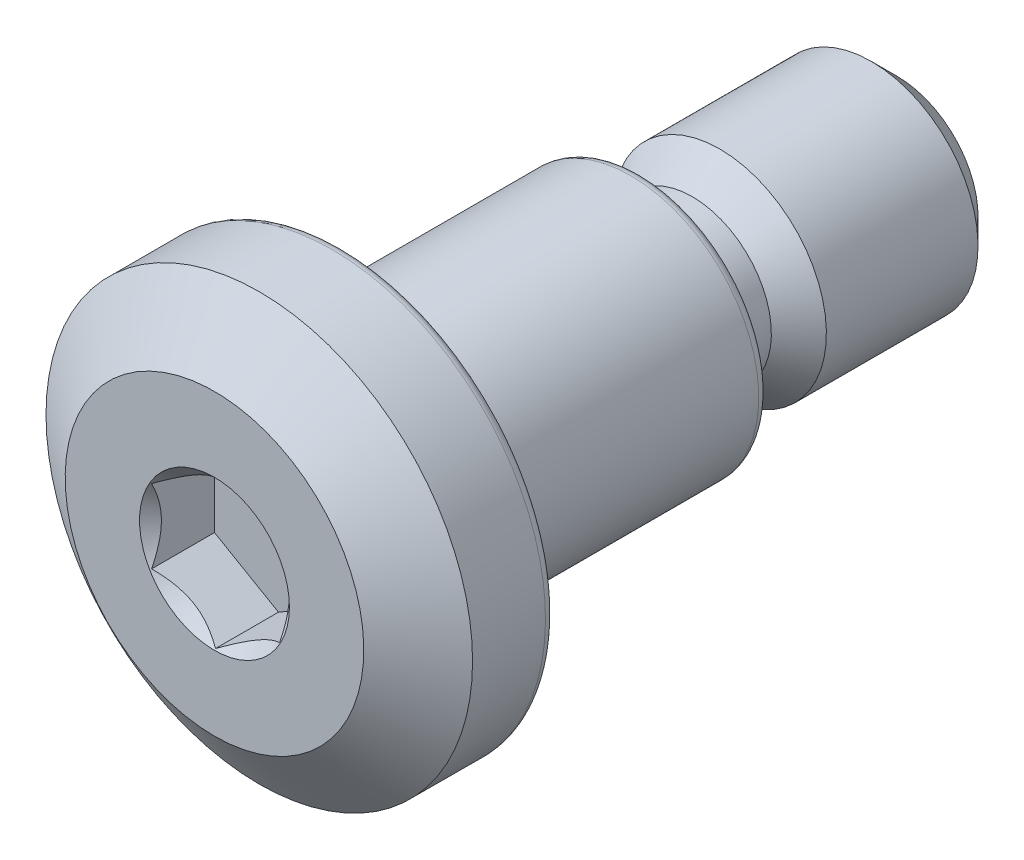
from build123d import *
from build123d.topology import SkipClean

# Parameters (mm, degrees)
CUT_REVOLVE1_ANGLE = 360
CUT_EXTRUDE2_DEPTH = 1.5
SKETCH9_R          = 1.757050808
CUT_EXTRUDE4_DEPTH = 1.5
CUT_EXTRUDE4_DRAFT = -45
CHAMFER1_SIZE      = 0.6
CHAMFER2_SIZE      = 1.5
CHAMFER2_SIZE2     = 1.050311307
FILLET1_R          = 0.24
SKETCH12_R         = 0.15
FILLET2_R          = 0.3


with BuildPart() as part:
    # Sketch10 → Revolve1 (revolve)
    with BuildSketch(Plane(origin=(0, 0, 0), x_dir=(0, 0, -1), z_dir=(1, 0, 0))):
        Polygon((10, 3), (10, 2.5), (16, 2.5), (16, 0), (0, 0), (0, 5), (3, 5), (3, 3), align=None)
    revolve(axis=Axis((0, 0, -16), (0, 0, 1)))

    # Sketch5 → Cut-Revolve1 (revolve, symmetric, cut)
    with SkipClean():  # the faces are left unmerged after this step: merging them gives an invalid solid
        with BuildSketch(Plane(origin=(0, 0, 0), x_dir=(0, 0, -1), z_dir=(1, 0, 0))) as cut_revolve1_sk:
            with BuildLine():
                Line((10, 3), (12.345, 3))
                Line((12.345, 3), (11.2, 1.855))
                Line((11.2, 1.855), (10.645, 1.855))
                ThreePointArc((10.645, 1.855), (10.188916126, 2.043916126), (10, 2.5))
                Line((10, 2.5), (10, 3))
            make_face()
        revolve(axis=Axis((0, 0, -16), (0, 0, 1)), revolution_arc=CUT_REVOLVE1_ANGLE / 2, mode=Mode.SUBTRACT)
        revolve(cut_revolve1_sk.sketch, axis=Axis((0, 0, -16), (0, 0, -1)), revolution_arc=CUT_REVOLVE1_ANGLE / 2, mode=Mode.SUBTRACT)

    # Sketch8 → Cut-Extrude2 (cut)
    with BuildSketch(Plane.XY):
        Polygon((0, 1.732050808), (-1.5, 0.866025404), (-1.5, -0.866025404), (0, -1.732050808), (1.5, -0.866025404), (1.5, 0.866025404), align=None)
    extrude(amount=-CUT_EXTRUDE2_DEPTH, mode=Mode.SUBTRACT)


with BuildPart() as cut_extrude4_tool:
    # Sketch9 → Cut-Extrude4 (with draft: the straight prism first)
    with BuildSketch(Plane.XY):
        Circle(SKETCH9_R)
    extrude(amount=-CUT_EXTRUDE4_DEPTH)
    # Cut-Extrude4: the draft: its side faces are tilted about the plane it starts from
    cut_extrude4_sides = [cut_extrude4_tool.faces().sort_by_distance(p)[0] for p in [
        (-1.757050808, 0, -0.75),
    ]]
    draft(cut_extrude4_sides, Plane.XY, CUT_EXTRUDE4_DRAFT)


with BuildPart() as part_1:
    add(part.part)

    # Cut-Extrude4: cut by cut_extrude4_tool
    add(cut_extrude4_tool.part, mode=Mode.SUBTRACT)

    # Chamfer1
    chamfer1_edges = [part_1.edges().sort_by_distance(p)[0] for p in [
        (0, -2.5, -16),
    ]]
    chamfer(chamfer1_edges, length=CHAMFER1_SIZE)

    # Chamfer2
    chamfer2_edges = [part_1.edges().sort_by_distance(p)[0] for p in [
        (0, -5, 0),
    ]]
    chamfer2_side = [part_1.faces().sort_by_distance(p)[0] for p in [
        (0, -4.858578644, 0),
    ]]
    chamfer(chamfer2_edges, length=CHAMFER2_SIZE, length2=CHAMFER2_SIZE2, reference=chamfer2_side[0])

    # Fillet1
    fillet1_edges = [part_1.edges().sort_by_distance(p)[0] for p in [
        (0, -5, -3),
        (0, -3, -10),
    ]]
    fillet(fillet1_edges, radius=FILLET1_R)

    # Sketch12 → Cut-Revolve2 (revolve, cut)
    with BuildSketch(Plane(origin=(0, 0, 0), x_dir=(0, 0, -1), z_dir=(1, 0, 0)), mode=Mode.PRIVATE) as cut_revolve2_sk:
        with Locations((3.15, 3)):
            Circle(SKETCH12_R)
    revolve(cut_revolve2_sk.sketch.rotate(Axis((0, 0, 0), (0, 0, -1)), 90), axis=Axis((0, 0, 0), (0, 0, -1)), mode=Mode.SUBTRACT)

    # Fillet2
    fillet2_edges = [part_1.edges().sort_by_distance(p)[0] for p in [
        (2.121320344, 2.121320344, -3.3),
    ]]
    fillet(fillet2_edges, radius=FILLET2_R)


solid = part_1.part
